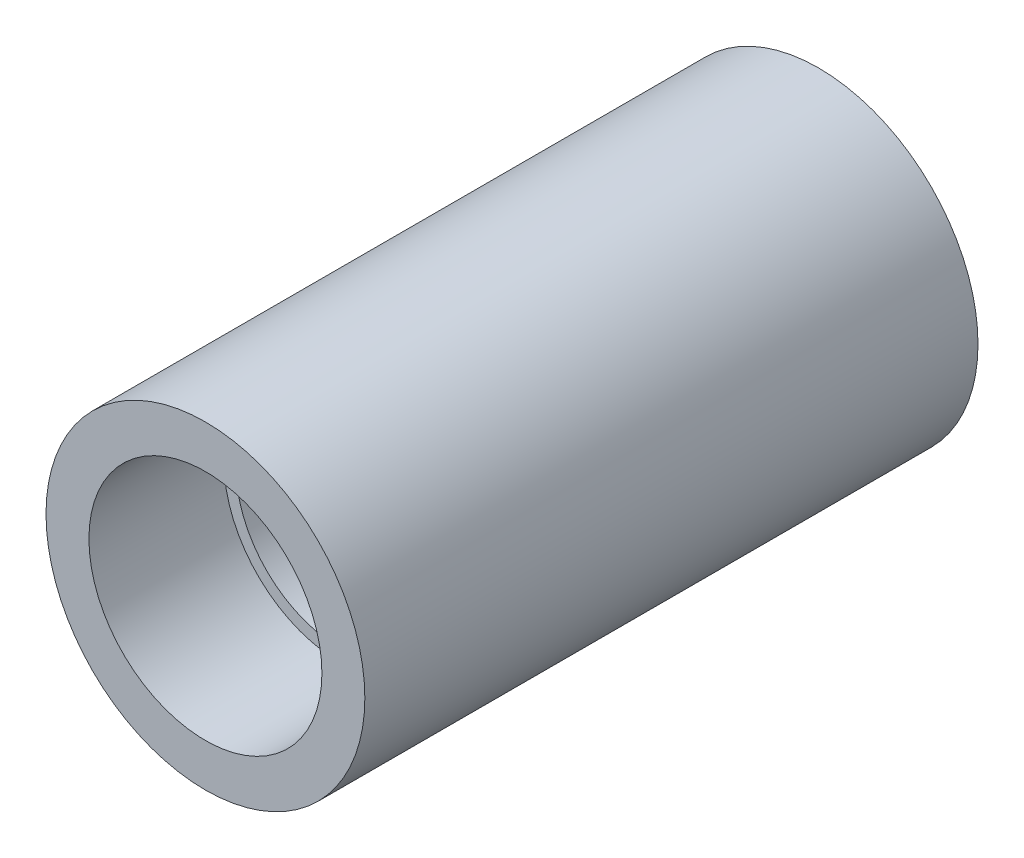
from build123d import *

# Parameters (mm, degrees)
SKETCH2_R           = 6.5
BOSS_EXTRUDE1_DEPTH = 25
SKETCH3_R           = 4.75
CUT_EXTRUDE1_DEPTH  = 5.5
SKETCH4_R           = 4.25
CUT_EXTRUDE2_DEPTH  = 5
SKETCH6_R           = 4.75
CUT_EXTRUDE3_DEPTH  = 7.5
CUT_EXTRUDE4_REACH  = 16.5
SKETCH7_R           = 2.75


with BuildPart() as part:
    # Sketch2 → Boss-Extrude1 (new body)
    with BuildSketch(Plane.XY):
        with Locations((5.654843538, 0)):
            Circle(SKETCH2_R)
    extrude(amount=BOSS_EXTRUDE1_DEPTH)

    # Sketch3 → Cut-Extrude1 (cut)
    with BuildSketch(Plane.XY.offset(25)):
        with Locations((5.654843538, 0)):
            Circle(SKETCH3_R)
    extrude(amount=-CUT_EXTRUDE1_DEPTH, mode=Mode.SUBTRACT)

    # Sketch4 → Cut-Extrude2 (cut)
    with BuildSketch(Plane.XY.offset(19.5)):
        with Locations((5.654843538, 0)):
            Circle(SKETCH4_R)
    extrude(amount=-CUT_EXTRUDE2_DEPTH, mode=Mode.SUBTRACT)

    # Sketch6 → Cut-Extrude3 (cut)
    with BuildSketch(Plane(origin=(0, 0, 0), x_dir=(-1, 0, 0), z_dir=(0, 0, -1))):
        with Locations((-5.654843538, 0)):
            Circle(SKETCH6_R)
    extrude(amount=-CUT_EXTRUDE3_DEPTH, mode=Mode.SUBTRACT)

    # Sketch7 → Cut-Extrude4 (cut, up to next)
    with BuildSketch(Plane.XY.offset(14.5), mode=Mode.PRIVATE) as cut_extrude4_sk1:
        with Locations((5.654843538, 0)):
            Circle(SKETCH7_R)
    cut_extrude4_tool1 = extrude(cut_extrude4_sk1.sketch, amount=-CUT_EXTRUDE4_REACH, mode=Mode.PRIVATE) & part.part
    add(cut_extrude4_tool1.solids().sort_by_distance((5.654844, 0, 14.5))[0], mode=Mode.SUBTRACT)


solid = part.part
